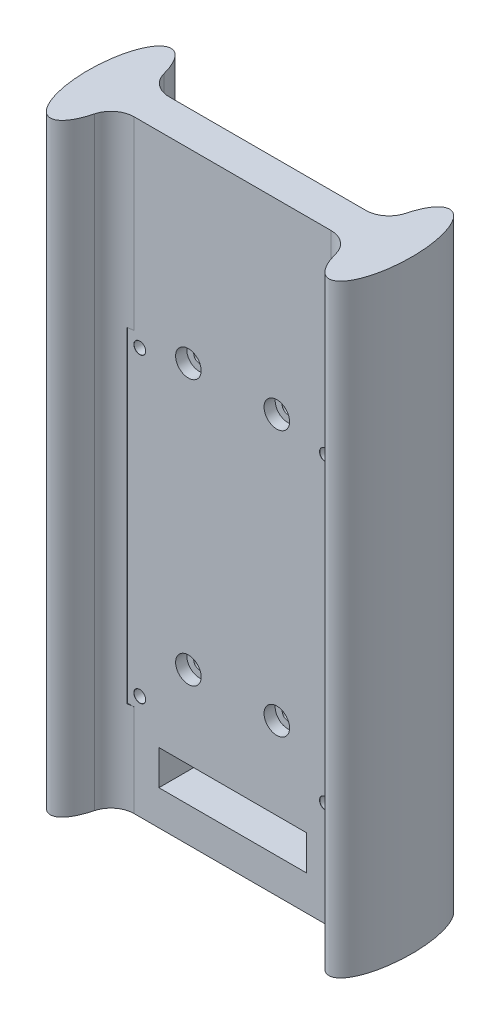
from build123d import *

# Parameters (mm, degrees)
BOSS_EXTRUDE1_DEPTH               = 130
FILLET1_R                         = 5
SKETCH3_W                         = 31.75
SKETCH3_H                         = 7.5
CUT_EXTRUDE2_DEPTH                = 10.2500001
CUT_EXTRUDE2_DEPTH_BACK           = 17.7500001
TAP_DRILL_FOR_M3X0_5_TAP1_D       = 2.5
SKETCH5_W                         = 45.2
SKETCH5_H                         = 70.2
SKETCH5_W_2                       = 35
SKETCH5_H_2                       = 60
CUT_EXTRUDE3_DEPTH                = 10
SKETCH6_R                         = 2.75
CUT_EXTRUDE4_DEPTH                = 2.4
TAP_DRILL_FOR_M3_TAP1_D           = 2.5
TAP_DRILL_FOR_M3_TAP1_CSINK_D     = 2.55
TAP_DRILL_FOR_M3_TAP1_CSINK_ANGLE = 90


with BuildPart() as part:
    # Sketch1 → Boss-Extrude1 (new body)
    with BuildSketch(Plane(origin=(0, 0, 0), x_dir=(1, 0, 0), z_dir=(0, 1, 0))):
        with BuildLine():
            add(Edge.make_bspline(
                [(25.356166305, 3.75), (24.934680795, 0), (25.356166305, -3.75)],
                knots=[1.278176641, 1.278176641, 1.278176641, 1.863416012, 1.863416012, 1.863416012], degree=2, weights=[1, 0.957491483, 1]))
            Line((25.356166305, 3.75), (-25.356166305, 3.75))
            add(Edge.make_bspline(
                [(-25.356166305, -3.75), (-24.934680795, 0), (-25.356166305, 3.75)],
                knots=[1.278176641, 1.278176641, 1.278176641, 1.863416012, 1.863416012, 1.863416012], degree=2, weights=[1, 0.957491483, 1]))
            Line((-25.356166305, -3.75), (25.356166305, -3.75))
        make_face()
        with BuildLine():
            add(Edge.make_bspline(
                [(-25.356166305, -3.75), (-24.934680795, 0), (-25.356166305, 3.75)],
                knots=[1.278176641, 1.278176641, 1.278176641, 1.863416012, 1.863416012, 1.863416012], degree=2, weights=[1, 0.957491483, 1]))
            Line((-25.356166305, 3.75), (-30, 3.75))
            Line((-30, 3.75), (-30, -3.75))
            Line((-30, -3.75), (-25.356166305, -3.75))
        make_face()
        with BuildLine():
            Line((-30, 3.75), (-25.356166305, 3.75))
            add(Edge.make_bspline(
                [(-25.356166305, 3.75), (-28.138876861, 28.508062419), (-33.892803395, 7.75403121), (-39.646729928, -13), (-30, -13)],
                knots=[1.863416012, 1.863416012, 1.863416012, 4.07330066, 4.07330066, 6.283185307, 6.283185307, 6.283185307], degree=2, weights=[1, 0.449185964, 1, 0.449185964, 1]))
            add(Edge.make_bspline(
                [(-30, -13), (-26.395830565, -13), (-25.356166305, -3.75)],
                knots=[0, 0, 0, 1.278176641, 1.278176641, 1.278176641], degree=2, weights=[1, 0.802639875, 1]))
            Line((-25.356166305, -3.75), (-30, -3.75))
            Line((-30, -3.75), (-30, 3.75))
        make_face()
        with BuildLine():
            Line((30, -3.75), (30, 3.75))
            Line((30, 3.75), (25.356166305, 3.75))
            add(Edge.make_bspline(
                [(25.356166305, 3.75), (24.934680795, 0), (25.356166305, -3.75)],
                knots=[1.278176641, 1.278176641, 1.278176641, 1.863416012, 1.863416012, 1.863416012], degree=2, weights=[1, 0.957491483, 1]))
            Line((25.356166305, -3.75), (30, -3.75))
        make_face()
        with BuildLine():
            Line((25.356166305, 3.75), (30, 3.75))
            Line((30, 3.75), (30, -3.75))
            Line((30, -3.75), (25.356166305, -3.75))
            add(Edge.make_bspline(
                [(25.356166305, -3.75), (28.138876861, -28.508062419), (33.892803395, -7.75403121), (39.646729928, 13), (30, 13)],
                knots=[1.863416012, 1.863416012, 1.863416012, 4.07330066, 4.07330066, 6.283185307, 6.283185307, 6.283185307], degree=2, weights=[1, 0.449185964, 1, 0.449185964, 1]))
            add(Edge.make_bspline(
                [(30, 13), (26.395830565, 13), (25.356166305, 3.75)],
                knots=[0, 0, 0, 1.278176641, 1.278176641, 1.278176641], degree=2, weights=[1, 0.802639875, 1]))
        make_face()
    extrude(amount=BOSS_EXTRUDE1_DEPTH)

    # Fillet1
    fillet1_edges = [part.edges().sort_by_distance(p)[0] for p in [
        (-25.356166305, 65, -3.75),
        (25.356166305, 65, -3.75),
        (25.356166305, 65, 3.75),
        (-25.356166305, 65, 3.75),
    ]]
    fillet(fillet1_edges, radius=FILLET1_R)

    # Sketch3 → Cut-Extrude2 (cut, two sides)
    with BuildSketch(Plane(origin=(0, 0, -3.75), x_dir=(-1, 0, 0), z_dir=(0, 0, -1))) as cut_extrude2_sk:
        with Locations((0, 11.25)):
            Rectangle(SKETCH3_W, SKETCH3_H)
    extrude(amount=CUT_EXTRUDE2_DEPTH, mode=Mode.SUBTRACT)
    extrude(cut_extrude2_sk.sketch, amount=-CUT_EXTRUDE2_DEPTH_BACK, mode=Mode.SUBTRACT)

    # Tap Drill for M3x0.5 Tap1 (through all)
    with Locations(Plane(origin=(9.525, 89.85, -3.75), x_dir=(-1, 0, 0), z_dir=(0, 0, -1))):
        with Locations((0, 0), (19.05, 0), (19.05, -57.15), (0, -57.15)):
            Hole(TAP_DRILL_FOR_M3X0_5_TAP1_D / 2)

    # Sketch5 → Cut-Extrude3 (cut)
    with BuildSketch(Plane.XY.offset(3.75)):
        with Locations((0, 55)):
            Rectangle(SKETCH5_W, SKETCH5_H)
        with Locations((0, 55)):
            Rectangle(SKETCH5_W_2, SKETCH5_H_2, mode=Mode.SUBTRACT)
    extrude(amount=CUT_EXTRUDE3_DEPTH, mode=Mode.SUBTRACT)

    # Sketch6 → Cut-Extrude4 (cut)
    with BuildSketch(Plane.XY.offset(3.75)):
        with Locations((9.525, 89.85)):
            Circle(SKETCH6_R)
        with Locations((-9.525, 89.85)):
            Circle(SKETCH6_R)
        with Locations((9.525, 32.7)):
            Circle(SKETCH6_R)
        with Locations((-9.525, 32.7)):
            Circle(SKETCH6_R)
    extrude(amount=-CUT_EXTRUDE4_DEPTH, mode=Mode.SUBTRACT)

    # Tap Drill for M3 Tap1 (through all)
    with Locations(Plane.XY.offset(3.75)):
        with Locations((-20, 87.5), (20, 87.5), (20, 22.5), (-20, 22.5)):
            CounterSinkHole(TAP_DRILL_FOR_M3_TAP1_D / 2, TAP_DRILL_FOR_M3_TAP1_CSINK_D / 2, counter_sink_angle=TAP_DRILL_FOR_M3_TAP1_CSINK_ANGLE)


solid = part.part
